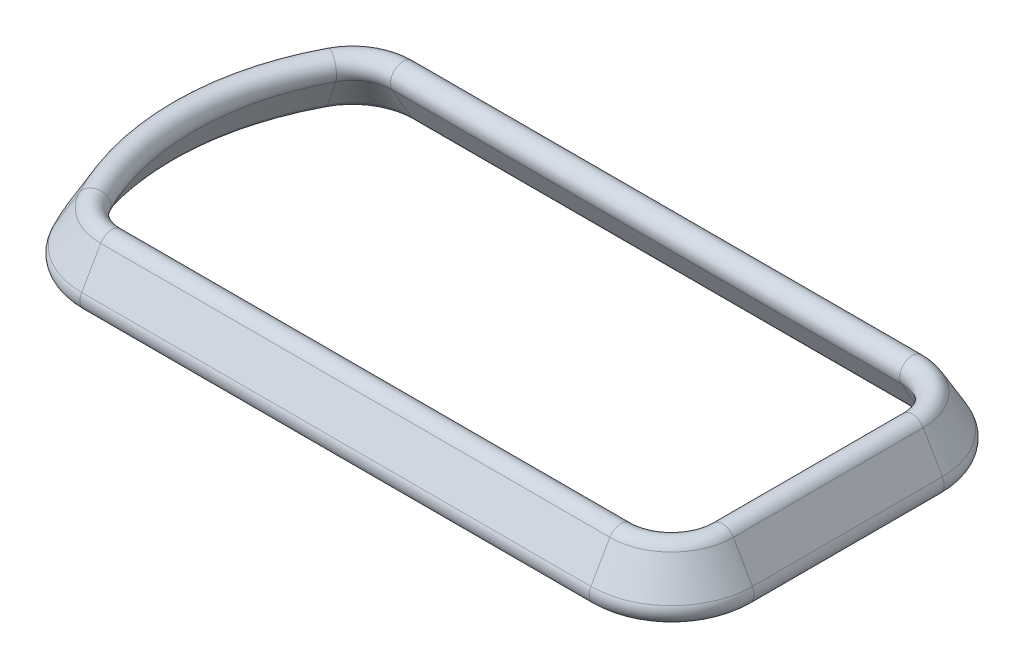
from build123d import *


with BuildPart() as part:
    # Austragung2: sweep along a path in Skizze1
    with BuildLine(Plane(origin=(0, 0, 0), x_dir=(1, 0, 0), z_dir=(0, 1, 0))) as austragung2_path:
        Line((-100.35104183, -57.432811357), (100.35104183, -57.432811357))
        ThreePointArc((100.35104183, -57.432811357), (114.493177454, -51.574946981), (120.35104183, -37.432811357))
        Line((120.35104183, -37.432811357), (120.35104183, 37.432811357))
        ThreePointArc((120.35104183, 37.432811357), (114.493177454, 51.574946981), (100.35104183, 57.432811357))
        Line((100.35104183, 57.432811357), (-100.35104183, 57.432811357))
        ThreePointArc((-100.35104183, 57.432811357), (-110.666950496, 54.567046922), (-118.026562745, 46.791014197))
        ThreePointArc((-118.026562745, 46.791014197), (-129.64895817, 0), (-118.026562745, -46.791014197))
        ThreePointArc((-118.026562745, -46.791014197), (-110.666950496, -54.567046922), (-100.35104183, -57.432811357))
    # Skizze2 → Austragung2 (sweep)
    with BuildSketch(Plane.XY):
        with BuildLine():
            Line((-125.318831151, -2.5), (-132.818831151, -15.490381057))
            ThreePointArc((-132.818831151, -15.490381057), (-139.64895817, -17.320508076), (-141.479085189, -10.490381057))
            Line((-141.479085189, -10.490381057), (-133.979085189, 2.5))
            ThreePointArc((-133.979085189, 2.5), (-127.14895817, 4.330127019), (-125.318831151, -2.5))
        make_face()
    sweep(path=austragung2_path.line)


solid = part.part
